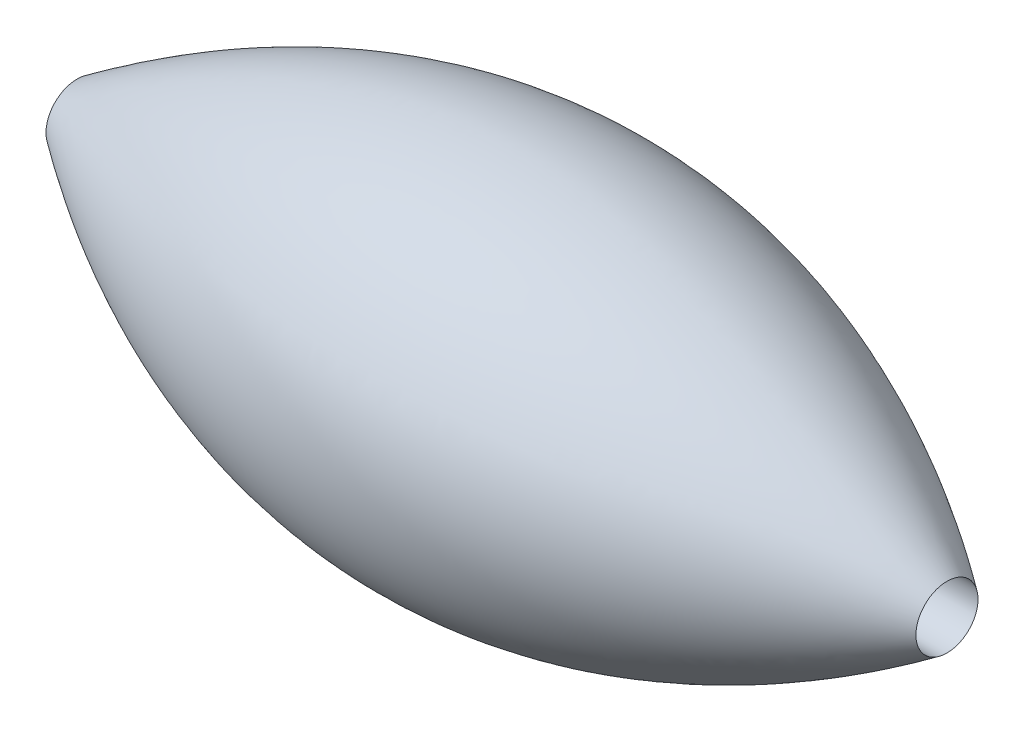
from build123d import *


with BuildPart() as part:
    # Sketch1 → Revolve1 (revolve)
    with BuildSketch(Plane.XY):
        with BuildLine():
            Line((0, 0), (28, 0))
            add(Edge.make_bspline(
                [(0, 0), (14, 10), (28, 0)],
                knots=[0, 0, 0, 1, 1, 1], degree=2))
        make_face()
    revolve(axis=Axis((0, -1, 0), (1, 0, 0)))


solid = part.part
